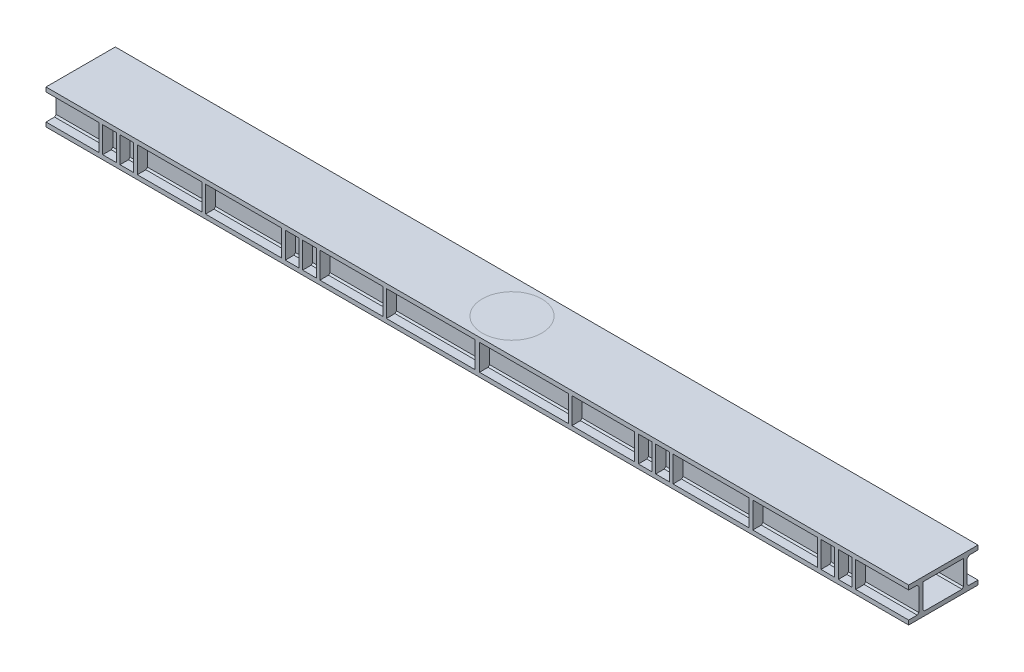
from build123d import *

# Parameters (mm, degrees)
SKETCH3_W           = 95
SKETCH3_H           = 180
SKETCH3_W_2         = 447.5
SKETCH3_W_3         = 527.35726118
SKETCH3_W_4         = 435.14237683
SKETCH3_W_5         = 615.00036199
SKETCH3_W_6         = 615.000361991
SKETCH3_W_7         = 527.357261179
BOSS_EXTRUDE1_DEPTH = 480
BOSS_EXTRUDE3_DEPTH = 5975


with BuildPart() as part:
    # Sketch3 → Boss-Extrude1 (new body)
    with BuildSketch(Plane.XY):
        Polygon((-1811.69761376, -161.976062081), (4163.30238624, -161.976062081), (4163.30238624, -131.976062081), (3795.80238624, -131.976062081), (3795.80238624, 48.023937919), (4163.30238624, 48.023937919), (4163.30238624, 78.023937919), (-1811.69761376, 78.023937919), (-1811.69761376, 48.023937919), (-1444.19761376, 48.023937919), (-1444.19761376, -131.976062081), (-1811.69761376, -131.976062081), align=None)
        with Locations((3723.30238624, -41.976062081)):
            Rectangle(SKETCH3_W, SKETCH3_H, mode=Mode.SUBTRACT)
        with Locations((3603.30238624, -41.976062081)):
            Rectangle(SKETCH3_W, SKETCH3_H, mode=Mode.SUBTRACT)
        with Locations((3307.05238624, -41.976062081)):
            Rectangle(SKETCH3_W_2, SKETCH3_H, mode=Mode.SUBTRACT)
        with Locations((2794.62375565, -41.976062081)):
            Rectangle(SKETCH3_W_3, SKETCH3_H, mode=Mode.SUBTRACT)
        with Locations((2458.44512506, -41.976062081)):
            Rectangle(SKETCH3_W, SKETCH3_H, mode=Mode.SUBTRACT)
        with Locations((2338.44512506, -41.976062081)):
            Rectangle(SKETCH3_W, SKETCH3_H, mode=Mode.SUBTRACT)
        with Locations((2048.373936645, -41.976062081)):
            Rectangle(SKETCH3_W_4, SKETCH3_H, mode=Mode.SUBTRACT)
        with Locations((1498.302567235, -41.976062081)):
            Rectangle(SKETCH3_W_5, SKETCH3_H, mode=Mode.SUBTRACT)
        with Locations((853.302205245, -41.976062081)):
            Rectangle(SKETCH3_W_6, SKETCH3_H, mode=Mode.SUBTRACT)
        with Locations((303.230835834, -41.976062081)):
            Rectangle(SKETCH3_W_4, SKETCH3_H, mode=Mode.SUBTRACT)
        with Locations((13.159647419, -41.976062081)):
            Rectangle(SKETCH3_W, SKETCH3_H, mode=Mode.SUBTRACT)
        with Locations((-106.840352581, -41.976062081)):
            Rectangle(SKETCH3_W, SKETCH3_H, mode=Mode.SUBTRACT)
        with Locations((-443.018983171, -41.976062081)):
            Rectangle(SKETCH3_W_7, SKETCH3_H, mode=Mode.SUBTRACT)
        with Locations((-955.44761376, -41.976062081)):
            Rectangle(SKETCH3_W_2, SKETCH3_H, mode=Mode.SUBTRACT)
        with Locations((-1251.69761376, -41.976062081)):
            Rectangle(SKETCH3_W, SKETCH3_H, mode=Mode.SUBTRACT)
        with Locations((-1371.69761376, -41.976062081)):
            Rectangle(SKETCH3_W, SKETCH3_H, mode=Mode.SUBTRACT)
    extrude(amount=BOSS_EXTRUDE1_DEPTH)

    # Sketch4 → Boss-Extrude3 (add)
    with BuildSketch(Plane.ZY.offset(1811.69761376)):
        Polygon((75, 48.023937919), (60.120453381, 48.023937919), (75, 34.659840777), align=None)
        Polygon((75, 48.023937919), (75, 34.659840777), (75, -121.369460363), (75, -131.976062081), (100, -131.976062081), (100, -121.369460363), (100, 48.023937919), align=None)
        Polygon((75, -131.976062081), (75, -121.369460363), (64.393398282, -131.976062081), align=None)
        Polygon((110.606601718, -131.976062081), (100, -121.369460363), (100, -131.976062081), align=None)
        Polygon((420.801204914, -131.976062081), (410, -121.567701384), (410, -131.976062081), align=None)
        Polygon((380, -131.976062081), (380, -121.321024675), (369.442056172, -131.976062081), align=None)
        Polygon((410, 48.023937919), (380, 48.023937919), (380, -121.321024675), (380, -131.976062081), (410, -131.976062081), (410, -121.567701384), (410, 33.852066109), align=None)
        Polygon((424.17187181, 48.023937919), (410, 48.023937919), (410, 33.852066109), align=None)
    extrude(amount=-BOSS_EXTRUDE3_DEPTH)


solid = part.part
